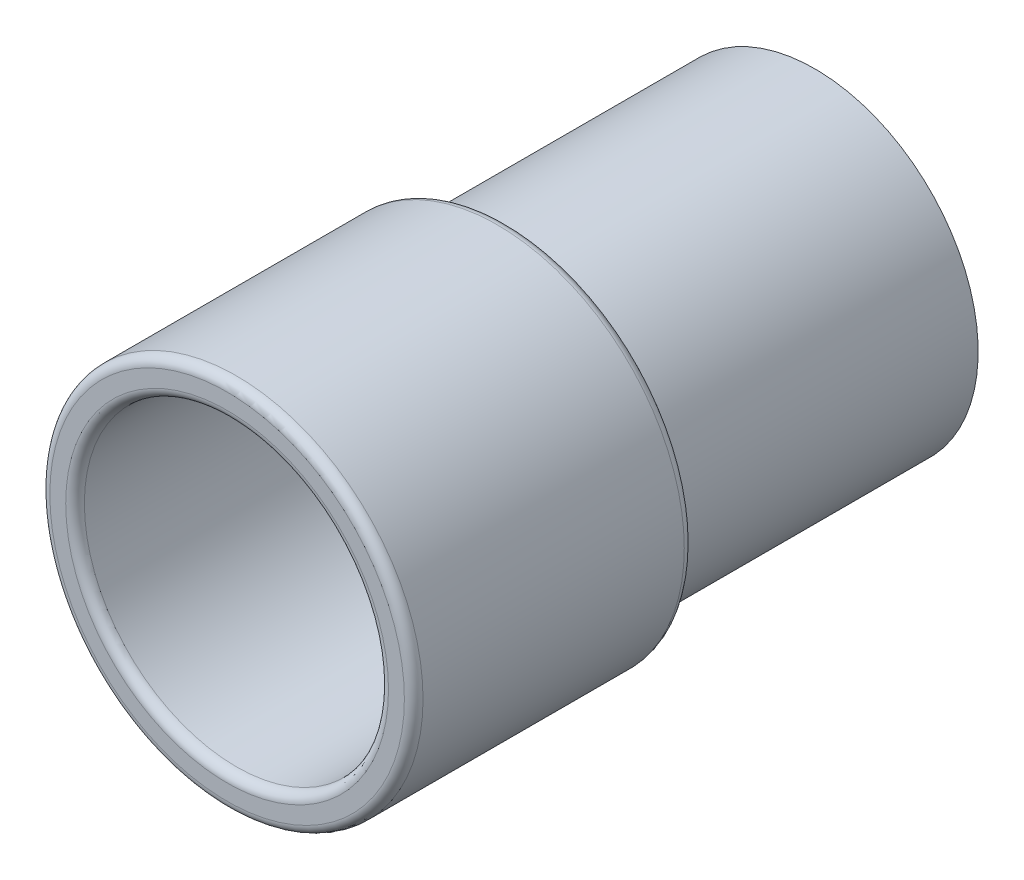
from build123d import *

# Parameters (mm, degrees)
SKETCH1_R           = 17.5
SKETCH1_R_2         = 15
BOSS_EXTRUDE1_DEPTH = 30
SKETCH2_R           = 20
SKETCH2_R_2         = 16.3
BOSS_EXTRUDE2_DEPTH = 30
SKETCH3_R           = 17.5
BOSS_EXTRUDE3_DEPTH = 3
CUT_EXTRUDE1_DEPTH  = 64
FILLET1_R           = 0.5
SKETCH5_R           = 3.5
CUT_EXTRUDE2_DEPTH  = 64
FILLET2_R           = 1
FILLET4_R           = 1
FILLET5_R           = 0.5


with BuildPart() as part:
    # Sketch1 → Boss-Extrude1 (new body)
    with BuildSketch(Plane.XY):
        Circle(SKETCH1_R)
        Circle(SKETCH1_R_2, mode=Mode.SUBTRACT)
    extrude(amount=BOSS_EXTRUDE1_DEPTH)

    # Sketch2 → Boss-Extrude2 (add)
    with BuildSketch(Plane.XY.offset(30)):
        Circle(SKETCH2_R)
        Circle(SKETCH2_R_2, mode=Mode.SUBTRACT)
    extrude(amount=BOSS_EXTRUDE2_DEPTH)

    # Sketch3 → Boss-Extrude3 (add)
    with BuildSketch(Plane(origin=(0, 0, 0), x_dir=(-1, 0, 0), z_dir=(0, 0, -1))):
        Circle(SKETCH3_R)
    extrude(amount=BOSS_EXTRUDE3_DEPTH)

    # Sketch4 → Cut-Extrude1 (cut, through all)
    with BuildSketch(Plane(origin=(0, 0, -3), x_dir=(-1, 0, 0), z_dir=(0, 0, -1))):
        Polygon((7.595087952, -8.142047722), (5.981728577, -5.25077993), (3.65460456, -6.549340845), (1.327480543, -7.847901761), (2.940839919, -10.739169553), align=None)
        Polygon((-1.327480543, 7.847901761), (-1.324474409, 7.842514531), (-3.65460456, 6.549340845), (-5.981728577, 5.25077993), (-7.595087952, 8.142047722), (-2.940839919, 10.739169553), align=None)
    extrude(amount=-CUT_EXTRUDE1_DEPTH, mode=Mode.SUBTRACT)

    # Fillet1
    fillet1_edges = [part.edges().sort_by_distance(p)[0] for p in [
        (-5.981728577, -5.25077993, -1.5),
        (-7.595087952, -8.142047722, -1.5),
        (-2.940839919, -10.739169553, -1.5),
        (-1.327480543, -7.847901761, -1.5),
        (2.940839919, 10.739169553, -1.5),
        (1.324474409, 7.842514531, -1.5),
        (5.981728577, 5.25077993, -1.5),
        (7.595087952, 8.142047722, -1.5),
    ]]
    fillet(fillet1_edges, radius=FILLET1_R)

    # Sketch5 → Cut-Extrude2 (cut, through all)
    with BuildSketch(Plane(origin=(0, 0, -3), x_dir=(-1, 0, 0), z_dir=(0, 0, -1))):
        Circle(SKETCH5_R)
    extrude(amount=-CUT_EXTRUDE2_DEPTH, mode=Mode.SUBTRACT)

    # Fillet2
    fillet2_edges = [part.edges().sort_by_distance(p)[0] for p in [
        (-20, 0, 60),
        (-20, 0, 30),
    ]]
    fillet(fillet2_edges, radius=FILLET2_R)

    # Fillet4
    fillet4_edges = [part.edges().sort_by_distance(p)[0] for p in [
        (-16.3, 0, 30),
        (-16.3, 0, 60),
        (-15, 0, 0),
    ]]
    fillet(fillet4_edges, radius=FILLET4_R)

    # Fillet5
    fillet5_edges = [part.edges().sort_by_distance(p)[0] for p in [
        (-15, 0, 30),
    ]]
    fillet(fillet5_edges, radius=FILLET5_R)


solid = part.part
